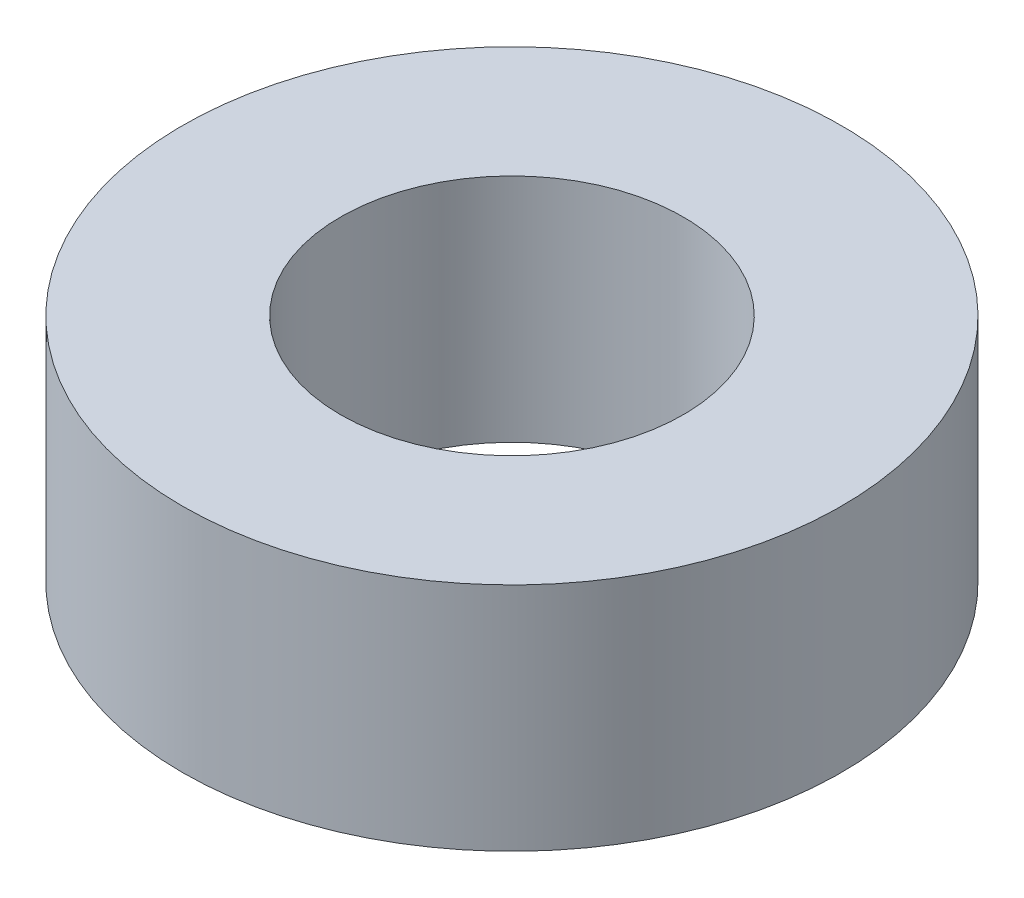
from build123d import *

# Parameters (mm, degrees)
SKETCH1_R           = 5
SKETCH1_R_2         = 2.6
BOSS_EXTRUDE1_DEPTH = 3.5


with BuildPart() as part:
    # Sketch1 → Boss-Extrude1 (new body)
    with BuildSketch(Plane(origin=(0, 0, 0), x_dir=(1, 0, 0), z_dir=(0, 1, 0))):
        Circle(SKETCH1_R)
        Circle(SKETCH1_R_2, mode=Mode.SUBTRACT)
    extrude(amount=BOSS_EXTRUDE1_DEPTH)


solid = part.part
